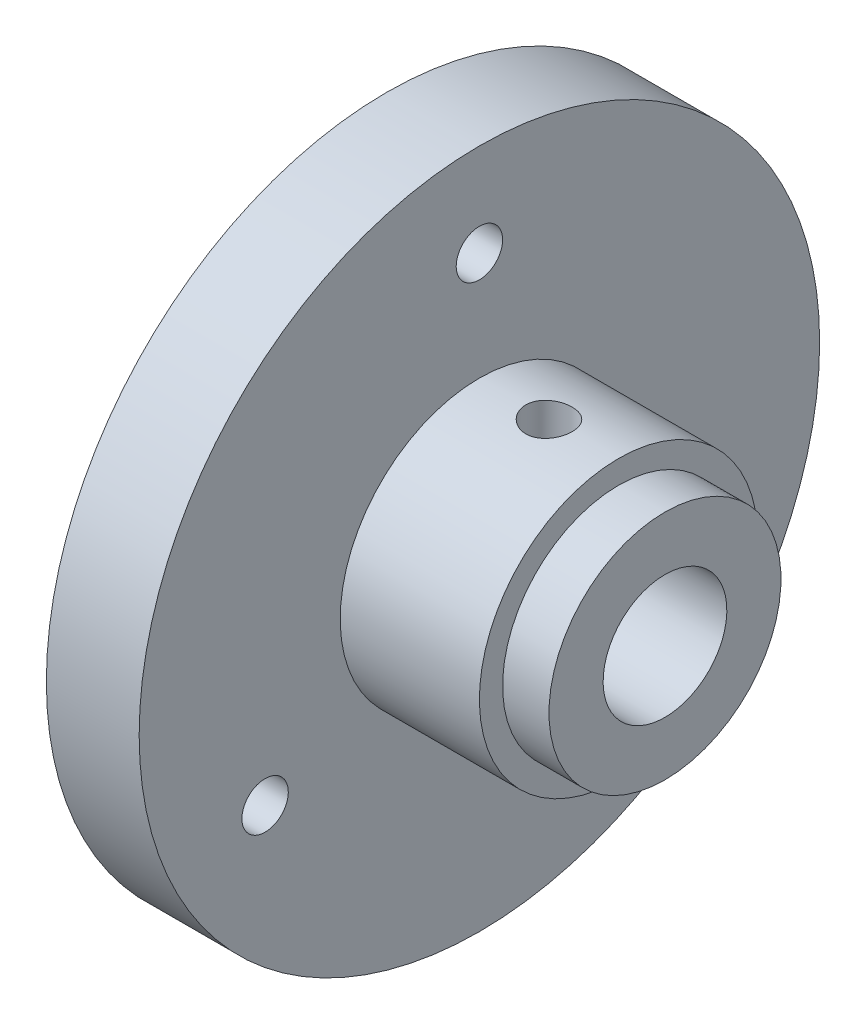
from build123d import *

# Parameters (mm, degrees)
ESQUISSE2_R             = 1.5
ENL_V_MAT_EXTRU_1_DEPTH = 7
ENL_V_MAT_EXTRU_2_REACH = 33
ESQUISSE3_R             = 1.5


with BuildPart() as part:
    # Esquisse1 → Révolution1 (revolve)
    with BuildSketch(Plane.XY):
        Polygon((0, 4), (-18, 4), (-18, 22), (-12, 22), (-12, 9), (-3, 9), (-3, 7.5), (0, 7.5), align=None)
    revolve(axis=Axis((0, 0, 0), (-1, 0, 0)))

    # Esquisse2 → Enlèv. mat.-Extru.1 (cut, through all)
    with BuildSketch(Plane(origin=(-12, 0, 0), x_dir=(0, 0, -1), z_dir=(1, 0, 0))):
        with Locations((0, 16)):
            Circle(ESQUISSE2_R)
        with Locations((13.856406461, -8)):
            Circle(ESQUISSE2_R)
        with Locations((-13.856406461, -8)):
            Circle(ESQUISSE2_R)
    extrude(amount=-ENL_V_MAT_EXTRU_1_DEPTH, mode=Mode.SUBTRACT)

    # Esquisse3 → Enlèv. mat.-Extru.2 (cut, up to next)
    with BuildSketch(Plane(origin=(0, 9, 0), x_dir=(1, 0, 0), z_dir=(0, 1, 0)), mode=Mode.PRIVATE) as enl_v_mat_extru_2_sk1:
        with Locations((-7.5, 0)):
            Circle(ESQUISSE3_R)
    enl_v_mat_extru_2_tool1 = extrude(enl_v_mat_extru_2_sk1.sketch, amount=-ENL_V_MAT_EXTRU_2_REACH, mode=Mode.PRIVATE) & part.part
    add(enl_v_mat_extru_2_tool1.solids().sort_by_distance((-7.5, 9, 0))[0], mode=Mode.SUBTRACT)


solid = part.part
